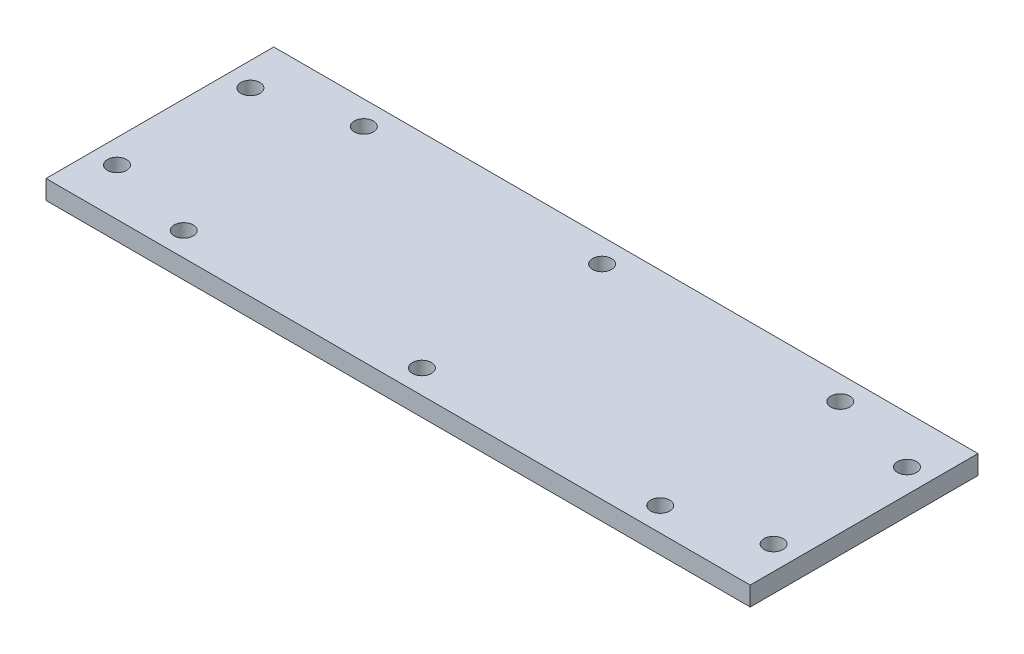
from build123d import *

# Parameters (mm, degrees)
SKETCH1_W           = 73.9
SKETCH1_H           = 23.9
SKETCH1_R           = 1
BOSS_EXTRUDE1_DEPTH = 2


with BuildPart() as part:
    # Sketch1 → Boss-Extrude1 (new body)
    with BuildSketch(Plane(origin=(0, 0, 0), x_dir=(1, 0, 0), z_dir=(0, 1, 0))):
        Rectangle(SKETCH1_W, SKETCH1_H)
        with Locations((-25, 9.45)):
            Circle(SKETCH1_R, mode=Mode.SUBTRACT)
        with Locations((0, 9.45)):
            Circle(SKETCH1_R, mode=Mode.SUBTRACT)
        with Locations((25, 9.45)):
            Circle(SKETCH1_R, mode=Mode.SUBTRACT)
        with Locations((-34.45, 7)):
            Circle(SKETCH1_R, mode=Mode.SUBTRACT)
        with Locations((25, -9.45)):
            Circle(SKETCH1_R, mode=Mode.SUBTRACT)
        with Locations((0, -9.45)):
            Circle(SKETCH1_R, mode=Mode.SUBTRACT)
        with Locations((-25, -9.45)):
            Circle(SKETCH1_R, mode=Mode.SUBTRACT)
        with Locations((-34.45, -7)):
            Circle(SKETCH1_R, mode=Mode.SUBTRACT)
        with Locations((34.45, -7)):
            Circle(SKETCH1_R, mode=Mode.SUBTRACT)
        with Locations((34.45, 7)):
            Circle(SKETCH1_R, mode=Mode.SUBTRACT)
    extrude(amount=BOSS_EXTRUDE1_DEPTH)


solid = part.part
